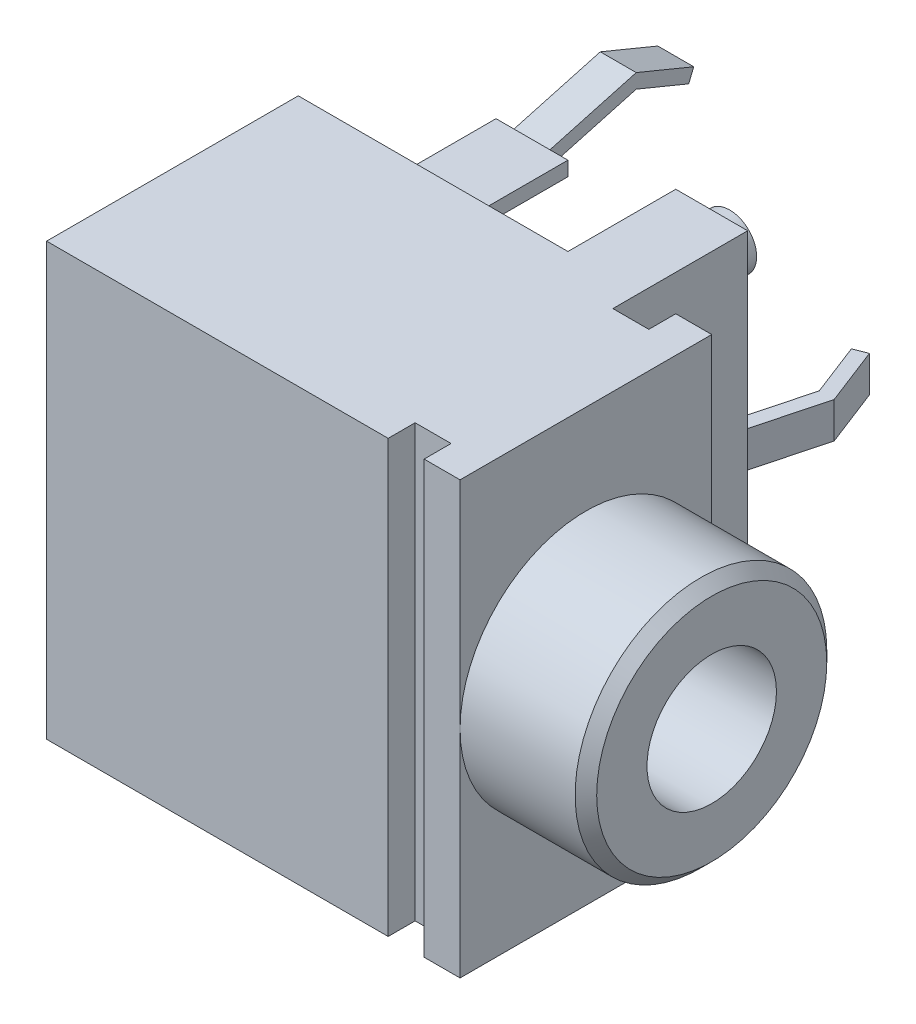
from build123d import *

# Parameters (mm, degrees)
ESBO_O1_W                        = 11.5
ESBO_O1_H                        = 12
RESSALTO_EXTRUS_O1_DEPTH         = 7
ESBO_O2_W                        = 10.5
ESBO_O2_H                        = 0.75
CORTE_EXTRUS_O1_DEPTH            = 13
ESBO_O3_W                        = 9.5
ESBO_O3_H                        = 12
RESSALTO_EXTRUS_O2_DEPTH         = 3.75
ESBO_O4_W                        = 7.5
ESBO_O4_H                        = 3
CORTE_EXTRUS_O2_DEPTH            = 13
ESBO_O5_W                        = 2
ESBO_O5_H                        = 0.4
RESSALTO_EXTRUS_O3_DEPTH         = 7
ESBO_O6_W                        = 0.5
ESBO_O6_H                        = 4
CORTE_EXTRUS_O3_DEPTH            = 9.7
ESBO_O7_W                        = 0.5
ESBO_O7_H                        = 4
CORTE_EXTRUS_O4_DEPTH            = 9.7
ESBO_O8_W                        = 4.75
ESBO_O8_H                        = 2
RESSALTO_EXTRUS_O4_DEPTH         = 3
ESBO_O9_W                        = 1
ESBO_O9_H                        = 0.75
CORTE_EXTRUS_O5_DEPTH            = 13
ESBO_O10_W                       = 2
ESBO_O10_H                       = 0.4
RESSALTO_EXTRUS_O5_DEPTH         = 3
ESBO_O11_W                       = 2
ESBO_O11_H                       = 0.4
RESSALTO_EXTRUS_O6_DEPTH         = 3
ESBO_O12_W                       = 2
ESBO_O12_H                       = 0.4
RESSALTO_EXTRUS_O7_DEPTH         = 3
ESBO_O13_W                       = 1
ESBO_O13_H                       = 0.4
RESSALTO_EXTRUS_O8_DEPTH         = 0.5
ESBO_O14_W                       = 0.75
ESBO_O14_H                       = 0.5
ESBO_O15_W                       = 0.75
ESBO_O15_H                       = 0.5
ESBO_O16_W                       = 3.5
ESBO_O16_H                       = 3.5
FURO_DE_DI_METRO_3_6_3_6_1_D     = 3.6
FURO_DE_DI_METRO_3_6_3_6_1_DEPTH = 3.5
CHANFRO1_SIZE                    = 0.3
ESBO_O19_W                       = 0.43
ESBO_O19_H                       = 1
RESSALTO_EXTRUS_O9_DEPTH         = 0.5
RESSALTO_EXTRUS_O10_DEPTH        = 0.5
RESSALTO_EXTRUS_O11_START        = -0.5
RESSALTO_EXTRUS_O11_DEPTH        = 1


with BuildPart() as part:
    # Esboço1 → Ressalto-extrusão1 (new body)
    with BuildSketch(Plane(origin=(0, 0, -3.5), x_dir=(-1, 0, 0), z_dir=(0, 0, -1))):
        with Locations((9.25, 0)):
            Rectangle(ESBO_O1_W, ESBO_O1_H)
    extrude(amount=-RESSALTO_EXTRUS_O1_DEPTH)

    # Esboço2 → Corte-extrusão1 (cut, through all)
    with BuildSketch(Plane(origin=(0, 6, 0), x_dir=(-1, 0, 0), z_dir=(0, 1, 0))):
        with Locations((9.75, -3.125)):
            Rectangle(ESBO_O2_W, ESBO_O2_H)
    extrude(amount=-CORTE_EXTRUS_O1_DEPTH, mode=Mode.SUBTRACT)

    # Esboço3 → Ressalto-extrusão2 (add)
    with BuildSketch(Plane(origin=(0, 0, -2.75), x_dir=(-1, 0, 0), z_dir=(0, 0, -1))):
        with Locations((10.25, 0)):
            Rectangle(ESBO_O3_W, ESBO_O3_H)
    extrude(amount=RESSALTO_EXTRUS_O2_DEPTH)

    # Esboço4 → Corte-extrusão2 (cut, through all)
    with BuildSketch(Plane.XZ.offset(6)):
        with Locations((-11.25, -5)):
            Rectangle(ESBO_O4_W, ESBO_O4_H)
    extrude(amount=-CORTE_EXTRUS_O2_DEPTH, mode=Mode.SUBTRACT)

    # Esboço5 → Ressalto-extrusão3 (add)
    with BuildSketch(Plane(origin=(0, 0, -3.5), x_dir=(-1, 0, 0), z_dir=(0, 0, -1))):
        with Locations((11.5, -2.5)):
            Rectangle(ESBO_O5_W, ESBO_O5_H)
    extrude(amount=RESSALTO_EXTRUS_O3_DEPTH)

    # Esboço6 → Corte-extrusão3 (cut, through all)
    with BuildSketch(Plane.XZ.offset(2.7)):
        with Locations((-10.75, -8.5)):
            Rectangle(ESBO_O6_W, ESBO_O6_H)
    extrude(amount=-CORTE_EXTRUS_O3_DEPTH, mode=Mode.SUBTRACT)

    # Esboço7 → Corte-extrusão4 (cut, through all)
    with BuildSketch(Plane.XZ.offset(2.7)):
        with Locations((-12.25, -8.5)):
            Rectangle(ESBO_O7_W, ESBO_O7_H)
    extrude(amount=-CORTE_EXTRUS_O4_DEPTH, mode=Mode.SUBTRACT)

    # Esboço8 → Ressalto-extrusão4 (add)
    with BuildSketch(Plane(origin=(0, 0, -3.5), x_dir=(-1, 0, 0), z_dir=(0, 0, -1))):
        with Locations((9.875, 0)):
            Rectangle(ESBO_O8_W, ESBO_O8_H)
    extrude(amount=RESSALTO_EXTRUS_O4_DEPTH)

    # Esboço9 → Corte-extrusão5 (cut, through all)
    with BuildSketch(Plane.XZ.offset(6)):
        with Locations((-5, 3.125)):
            Rectangle(ESBO_O9_W, ESBO_O9_H)
    extrude(amount=-CORTE_EXTRUS_O5_DEPTH, mode=Mode.SUBTRACT)

    # Esboço10 → Ressalto-extrusão5 (add)
    with BuildSketch(Plane(origin=(0, 0, -3.5), x_dir=(-1, 0, 0), z_dir=(0, 0, -1))):
        with Locations((11.5, 5)):
            Rectangle(ESBO_O10_W, ESBO_O10_H)
    extrude(amount=RESSALTO_EXTRUS_O5_DEPTH)

    # Esboço11 → Ressalto-extrusão6 (add)
    with BuildSketch(Plane(origin=(0, 0, -3.5), x_dir=(-1, 0, 0), z_dir=(0, 0, -1))):
        with Locations((11.5, -5)):
            Rectangle(ESBO_O11_W, ESBO_O11_H)
    extrude(amount=RESSALTO_EXTRUS_O6_DEPTH)

    # Esboço12 → Ressalto-extrusão7 (add)
    with BuildSketch(Plane(origin=(0, 0, -3.5), x_dir=(-1, 0, 0), z_dir=(0, 0, -1))):
        with Locations((11.5, 2.5)):
            Rectangle(ESBO_O12_W, ESBO_O12_H)
    extrude(amount=RESSALTO_EXTRUS_O7_DEPTH)

    # Esboço13 → Ressalto-extrusão8 (add)
    with BuildSketch(Plane(origin=(0, 0, -6.5), x_dir=(-1, 0, 0), z_dir=(0, 0, -1))):
        with Locations((11.5, 0)):
            Rectangle(ESBO_O13_W, ESBO_O13_H)
    extrude(amount=RESSALTO_EXTRUS_O8_DEPTH)

    # Esboço14 → Revolução1 (revolve)
    with BuildSketch(Plane(origin=(0, -5, 0), x_dir=(1, 0, 0), z_dir=(0, 1, 0))):
        with Locations((-6.125, 6.75)):
            Rectangle(ESBO_O14_W, ESBO_O14_H)
    revolve(axis=Axis((-6.5, -5, -7), (0, 0, 1)))

    # Esboço15 → Revolução2 (revolve)
    with BuildSketch(Plane(origin=(0, 5, 0), x_dir=(1, 0, 0), z_dir=(0, 1, 0))):
        with Locations((-6.125, 6.75)):
            Rectangle(ESBO_O15_W, ESBO_O15_H)
    revolve(axis=Axis((-6.5, 5, -7), (0, 0, 1)))

    # Esboço16 → Revolução3 (revolve)
    with BuildSketch(Plane(origin=(0, 0, 0), x_dir=(-1, 0, 0), z_dir=(0, 0, -1))):
        with Locations((1.75, 1.75)):
            Rectangle(ESBO_O16_W, ESBO_O16_H)
    revolve(axis=Axis((0, 0, 0), (-1, 0, 0)))

    # Furo de diâmetro Ø3.6 (3.6)1
    with Locations(Plane(origin=(0, 0, 0), x_dir=(0, 0, -1), z_dir=(1, 0, 0))):
        with Locations((0, 0)):
            Hole(FURO_DE_DI_METRO_3_6_3_6_1_D / 2, depth=FURO_DE_DI_METRO_3_6_3_6_1_DEPTH)

    # Chanfro1
    chanfro1_edges = [part.edges().sort_by_distance(p)[0] for p in [
        (0, -3.5, 0),
    ]]
    chamfer(chanfro1_edges, length=CHANFRO1_SIZE)

    # Esboço19 → Ressalto-extrusão9 (add)
    with BuildSketch(Plane(origin=(0, 0, -6.5), x_dir=(-1, 0, 0), z_dir=(0, 0, -1))):
        with Locations((6.505, 0)):
            Rectangle(ESBO_O19_W, ESBO_O19_H)
    extrude(amount=RESSALTO_EXTRUS_O9_DEPTH)

    # Esboço20 → Ressalto-extrusão10 (add, symmetric)
    with BuildSketch(Plane(origin=(0, 0, 0), x_dir=(1, 0, 0), z_dir=(0, 1, 0))):
        Polygon((-6.302158206, 6.98750552), (-5.732158206, 9.13750552), (-6.352158206, 10.73750552), (-6.713447386, 10.597505963), (-6.147697214, 9.13750552), (-6.717697214, 6.98750552), align=None)
    extrude(amount=RESSALTO_EXTRUS_O10_DEPTH, both=True)

    # Esboço21 → Ressalto-extrusão11 (add)
    with BuildSketch(Plane.ZY.offset(12.5).offset(RESSALTO_EXTRUS_O11_START)):
        Polygon((-6.5, 5.2), (-8.9, 5.86), (-10.5, 5.2), (-10.35899319, 4.858165309), (-8.9, 5.46), (-6.5, 4.8), align=None)
    ressalto_extrus_o11 = extrude(amount=-RESSALTO_EXTRUS_O11_DEPTH)

    # Espelhar1: Ressalto-extrusão11 across plane
    add(ressalto_extrus_o11.mirror(Plane.ZX))


solid = part.part
